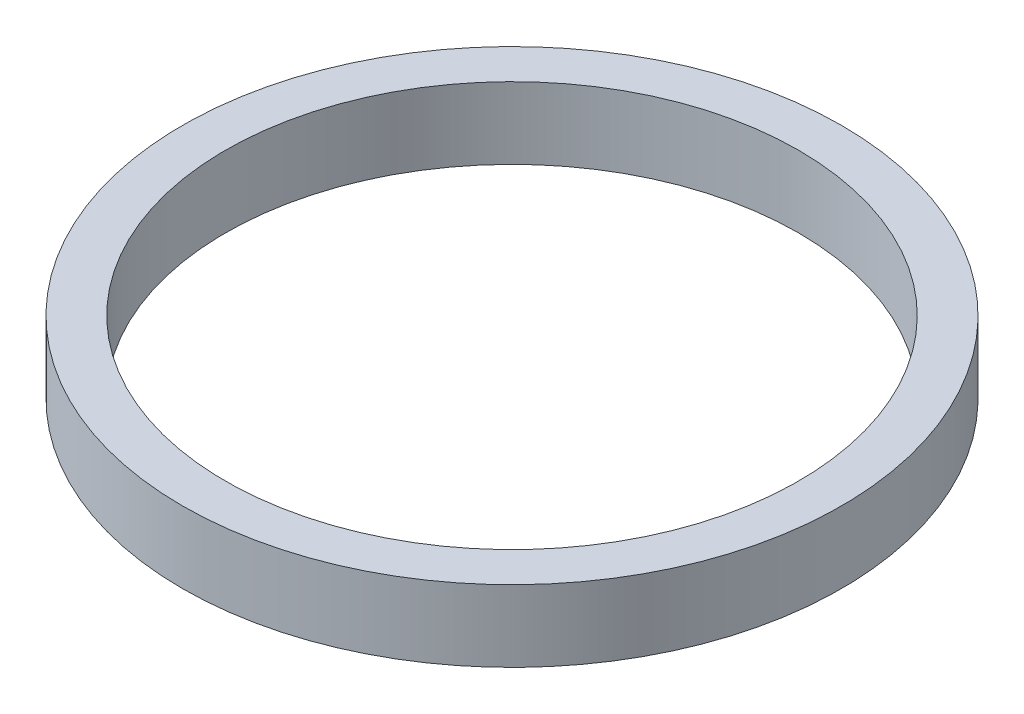
from build123d import *

# Parameters (mm, degrees)
SKETCH_1_W = 1.5
SKETCH_1_H = 2.5


with BuildPart() as part:
    # Эскиз1 → Повернуть1 (revolve)
    with BuildSketch(Plane.XY):
        with Locations((10.75, 1.25)):
            Rectangle(SKETCH_1_W, SKETCH_1_H)
    revolve(axis=Axis((0, 0, 0), (0, 1, 0)))


solid = part.part
